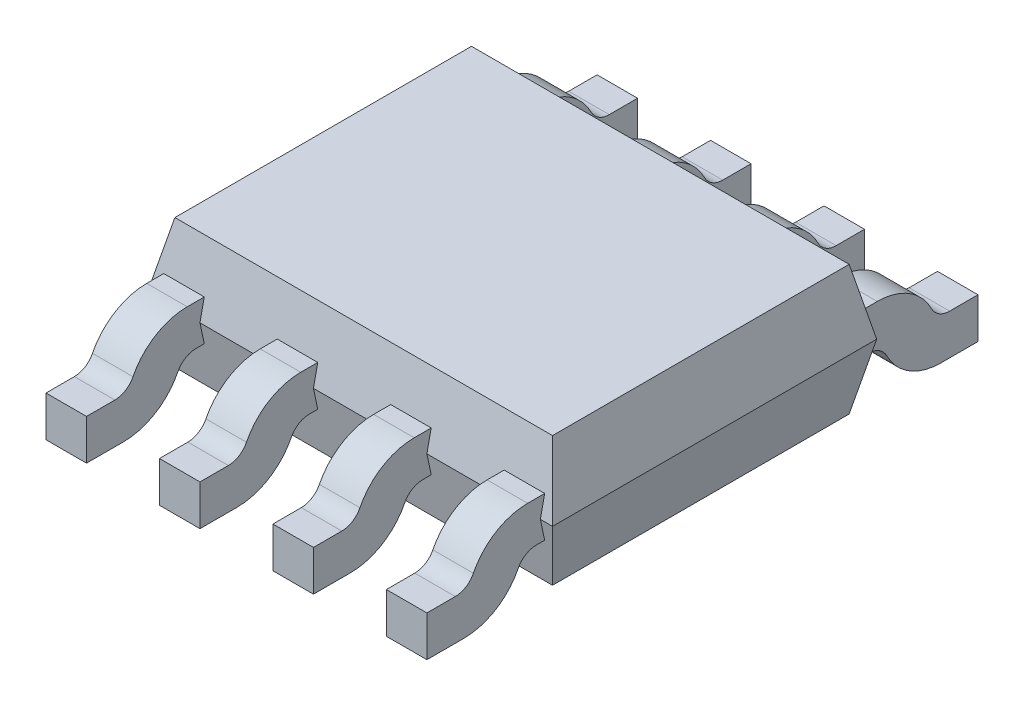
from build123d import *

# Parameters (mm, degrees)
SKETCH1_W                     = 5
SKETCH1_H                     = 4
BOSS_EXTRUDE1_DEPTH           = 0.8
BOSS_EXTRUDE1_TAPER           = 12
BOSS_EXTRUDE1_OTHER_WAY_DEPTH = 0.8
BOSS_EXTRUDE1_OTHER_WAY_TAPER = 12
SKETCH2_W                     = 0.5
SKETCH2_H                     = 0.5
BOSS_EXTRUDE3_DEPTH           = 0.8
BOSS_EXTRUDE3_DEPTH_BACK      = 1
SKETCH3_W                     = 0.5
SKETCH3_H                     = 0.5
BOSS_EXTRUDE4_DEPTH           = 0.55
SKETCH4_W                     = 0.5
SKETCH4_H                     = 0.5
BOSS_EXTRUDE5_DEPTH           = 0.6
FILLET1_R                     = 0.25
FILLET2_R                     = 0.75
LPATTERN2_COUNT               = 4
LPATTERN2_PITCH               = 1.4


with BuildPart() as part:
    # Sketch1 → Boss-Extrude1 (new body)
    with BuildSketch(Plane(origin=(0, 0, 0), x_dir=(1, 0, 0), z_dir=(0, 1, 0))):
        Rectangle(SKETCH1_W, SKETCH1_H)
    extrude(amount=BOSS_EXTRUDE1_DEPTH, taper=BOSS_EXTRUDE1_TAPER)

    # Sketch1 → Boss-Extrude1 other way (add)
    with BuildSketch(Plane(origin=(0, 0, 0), x_dir=(1, 0, 0), z_dir=(0, 1, 0))):
        Rectangle(SKETCH1_W, SKETCH1_H)
    extrude(amount=-BOSS_EXTRUDE1_OTHER_WAY_DEPTH, taper=BOSS_EXTRUDE1_OTHER_WAY_TAPER)


with BuildPart() as body_2:
    # Sketch2 → Boss-Extrude3 (new body, two sides)
    with BuildSketch(Plane.XY.offset(2)) as boss_extrude3_sk:
        with Locations((2.1, 0)):
            Rectangle(SKETCH2_W, SKETCH2_H)
    extrude(amount=BOSS_EXTRUDE3_DEPTH)
    extrude(boss_extrude3_sk.sketch, amount=-BOSS_EXTRUDE3_DEPTH_BACK)

    # Sketch3 → Boss-Extrude4 (add)
    with BuildSketch(Plane(origin=(0, -0.25, 0), x_dir=(-1, 0, 0), z_dir=(0, -1, 0))):
        with Locations((-2.1, -2.55)):
            Rectangle(SKETCH3_W, SKETCH3_H)
    extrude(amount=BOSS_EXTRUDE4_DEPTH)

    # Sketch4 → Boss-Extrude5 (add)
    with BuildSketch(Plane.XY.offset(2.8)):
        with Locations((2.1, -0.55)):
            Rectangle(SKETCH4_W, SKETCH4_H)
    extrude(amount=BOSS_EXTRUDE5_DEPTH)

    # Fillet1
    fillet1_edges = [body_2.edges().sort_by_distance(p)[0] for p in [
        (2.1, -0.25, 2.3),
        (2.1, -0.3, 2.8),
    ]]
    fillet(fillet1_edges, radius=FILLET1_R)

    # Fillet2
    fillet2_edges = [body_2.edges().sort_by_distance(p)[0] for p in [
        (2.1, -0.8, 2.3),
        (2.1, 0.25, 2.8),
    ]]
    fillet(fillet2_edges, radius=FILLET2_R)


with BuildPart() as lpattern2_1:
    # LPattern2: pattern copy
    add(body_2.part.moved(Location(Vector(-1, 0, 0) * (1 * LPATTERN2_PITCH))))


with BuildPart() as lpattern2_2:
    # LPattern2: pattern copy
    add(body_2.part.moved(Location(Vector(-1, 0, 0) * (2 * LPATTERN2_PITCH))))


with BuildPart() as lpattern2_3:
    # LPattern2: pattern copy
    add(body_2.part.moved(Location(Vector(-1, 0, 0) * (3 * LPATTERN2_PITCH))))


with BuildPart() as body_6:
    # Mirror2: mirrored copy
    add(body_2.part.mirror(Plane.XY))


with BuildPart() as body_7:
    # Mirror2 2: mirrored copy
    add(lpattern2_1.part.mirror(Plane.XY))


with BuildPart() as body_8:
    # Mirror2 3: mirrored copy
    add(lpattern2_2.part.mirror(Plane.XY))


with BuildPart() as body_9:
    # Mirror2 4: mirrored copy
    add(lpattern2_3.part.mirror(Plane.XY))


solid = Compound([part.part, body_2.part, lpattern2_1.part, lpattern2_2.part, lpattern2_3.part, body_6.part, body_7.part, body_8.part, body_9.part])
